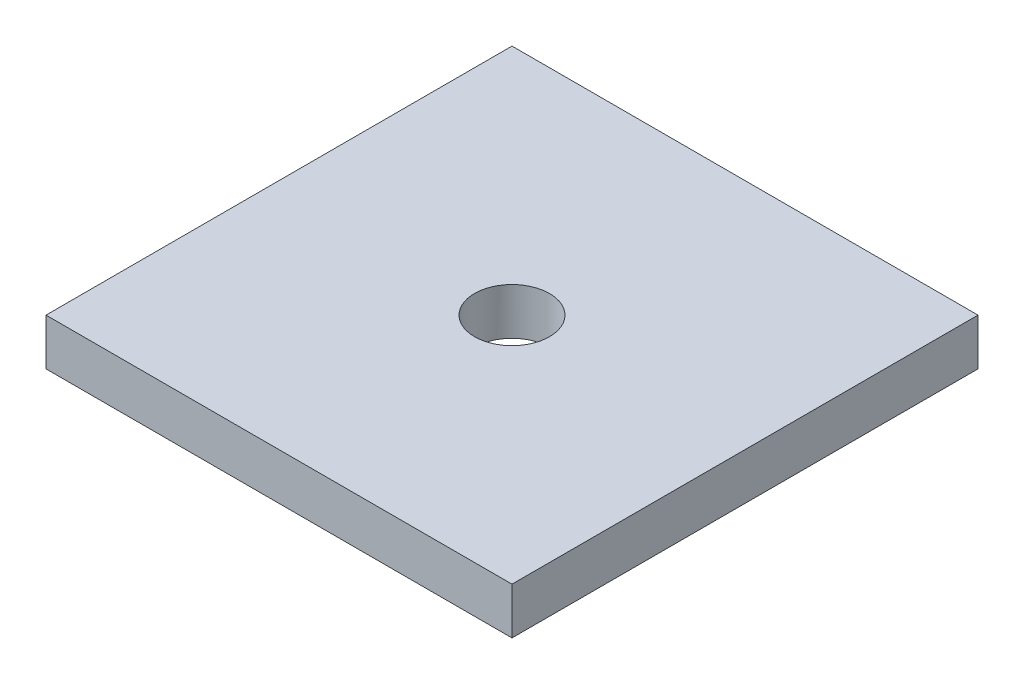
from build123d import *

# Parameters (mm, degrees)
SKETCH1_W                   = 31.75
SKETCH1_H                   = 31.75
BOSS_EXTRUDE1_DEPTH         = 3.175
F_1_4_20_TAPPED_HOLE1_D     = 5.1054
F_1_4_20_TAPPED_HOLE1_DEPTH = 16.51
F_1_4_20_TAPPED_HOLE1_TIP   = 1.533816902


with BuildPart() as part:
    # Sketch1 → Boss-Extrude1 (new body)
    with BuildSketch(Plane(origin=(0, 0, 0), x_dir=(1, 0, 0), z_dir=(0, 1, 0))):
        with Locations((15.875, 15.875)):
            Rectangle(SKETCH1_W, SKETCH1_H)
    extrude(amount=BOSS_EXTRUDE1_DEPTH)

    # 1/4-20 Tapped Hole1
    with Locations(Plane(origin=(0, 3.175, 0), x_dir=(1, 0, 0), z_dir=(0, 1, 0))):
        with Locations((15.875, 15.875)):
            Hole(F_1_4_20_TAPPED_HOLE1_D / 2, depth=F_1_4_20_TAPPED_HOLE1_DEPTH)
            with Locations((0, 0, -(F_1_4_20_TAPPED_HOLE1_DEPTH + F_1_4_20_TAPPED_HOLE1_TIP / 2))):  # 118° drill point
                Cone(0, F_1_4_20_TAPPED_HOLE1_D / 2, F_1_4_20_TAPPED_HOLE1_TIP, mode=Mode.SUBTRACT)


solid = part.part
